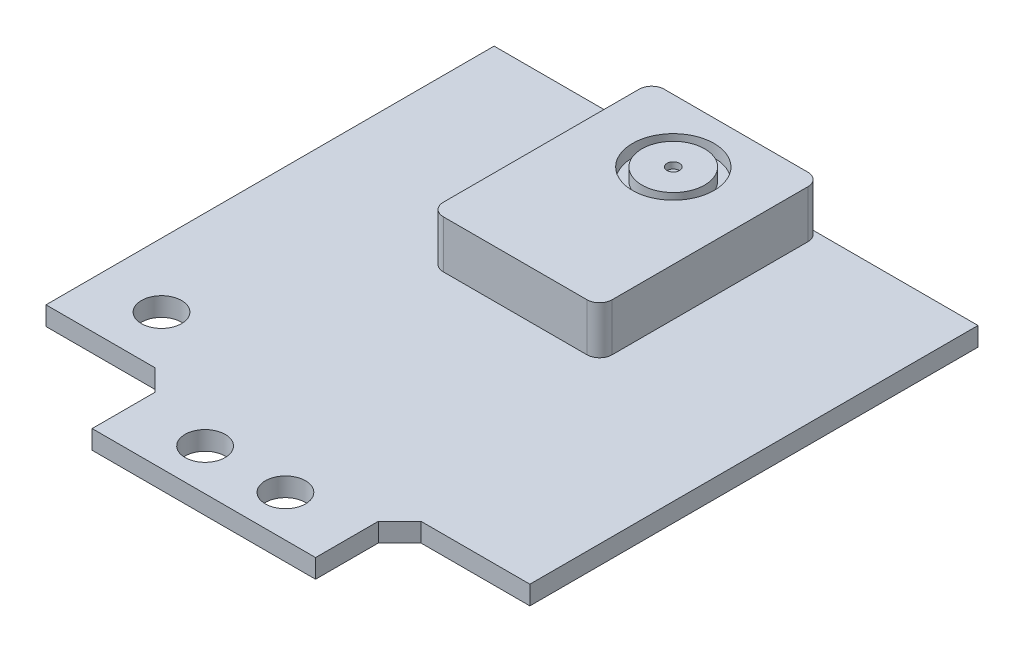
from build123d import *

# Parameters (mm, degrees)
SKETCH_1_R          = 1.6
EXTRUDE_1_DEPTH     = 1.5
EXTRUDE_START       = 1.5
EXTRUDE_2_DEPTH     = 3.8
CUT_EXTRUDE_START   = 5.3
SKETCH_1_4_R        = 3.25
SKETCH_1_4_R_2      = 2.5
CUT_EXTRUDE_1_DEPTH = 1
SKETCH_2_R          = 0.5
CUT_EXTRUDE_2_DEPTH = 0.5


with BuildPart() as part:
    # Sketch 1 → Extrude 1 (new body)
    with BuildSketch(Plane(origin=(0, 0, 0), x_dir=(1, 0, 0), z_dir=(0, 1, 0))):
        Polygon((-19.275, 17.85), (19.275, 17.85), (19.275, -17.85), (10.6, -17.85), (8.9, -19.55), (8.9, -24.55), (-8.9, -24.55), (-8.9, -19.55), (-10.6, -17.85), (-19.275, -17.85), align=None)
        with Locations((-14.175, -13.75)):
            Circle(SKETCH_1_R, mode=Mode.SUBTRACT)
        with Locations((-3.2, -21.25)):
            Circle(SKETCH_1_R, mode=Mode.SUBTRACT)
        with Locations((3.2, -21.25)):
            Circle(SKETCH_1_R, mode=Mode.SUBTRACT)
    extrude(amount=EXTRUDE_1_DEPTH)


with BuildPart() as body_2:
    # Sketch 1_3 → Extrude 2 (new body)
    with BuildSketch(Plane(origin=(0, 0, 0), x_dir=(1, 0, 0), z_dir=(0, 1, 0)).offset(EXTRUDE_START)):
        with BuildLine():
            Line((5.725, 0.25), (-5.725, 0.25))
            ThreePointArc((-5.725, 0.25), (-6.432106781, 0.542893219), (-6.725, 1.25))
            Line((-6.725, 1.25), (-6.725, 16.85))
            ThreePointArc((-6.725, 16.85), (-6.432106781, 17.557106781), (-5.725, 17.85))
            Line((-5.725, 17.85), (5.725, 17.85))
            ThreePointArc((5.725, 17.85), (6.432106781, 17.557106781), (6.725, 16.85))
            Line((6.725, 16.85), (6.725, 1.25))
            ThreePointArc((6.725, 1.25), (6.432106781, 0.542893219), (5.725, 0.25))
        make_face()
    extrude(amount=EXTRUDE_2_DEPTH)

    # Sketch 1_4 → Cut-Extrude 1 (cut)
    with BuildSketch(Plane(origin=(0, 0, 0), x_dir=(1, 0, 0), z_dir=(0, 1, 0)).offset(CUT_EXTRUDE_START)):
        with Locations((0, 12.85)):
            Circle(SKETCH_1_4_R)
        with Locations((0, 12.85)):
            Circle(SKETCH_1_4_R_2, mode=Mode.SUBTRACT)
    extrude(amount=-CUT_EXTRUDE_1_DEPTH, mode=Mode.SUBTRACT)

    # Sketch 2 → Cut-Extrude 2 (cut)
    with BuildSketch(Plane(origin=(0, 5.3, 0), x_dir=(1, 0, 0), z_dir=(0, 1, 0))):
        with Locations((0, 12.85)):
            Circle(SKETCH_2_R)
    extrude(amount=-CUT_EXTRUDE_2_DEPTH, mode=Mode.SUBTRACT)


solid = Compound([part.part, body_2.part])
